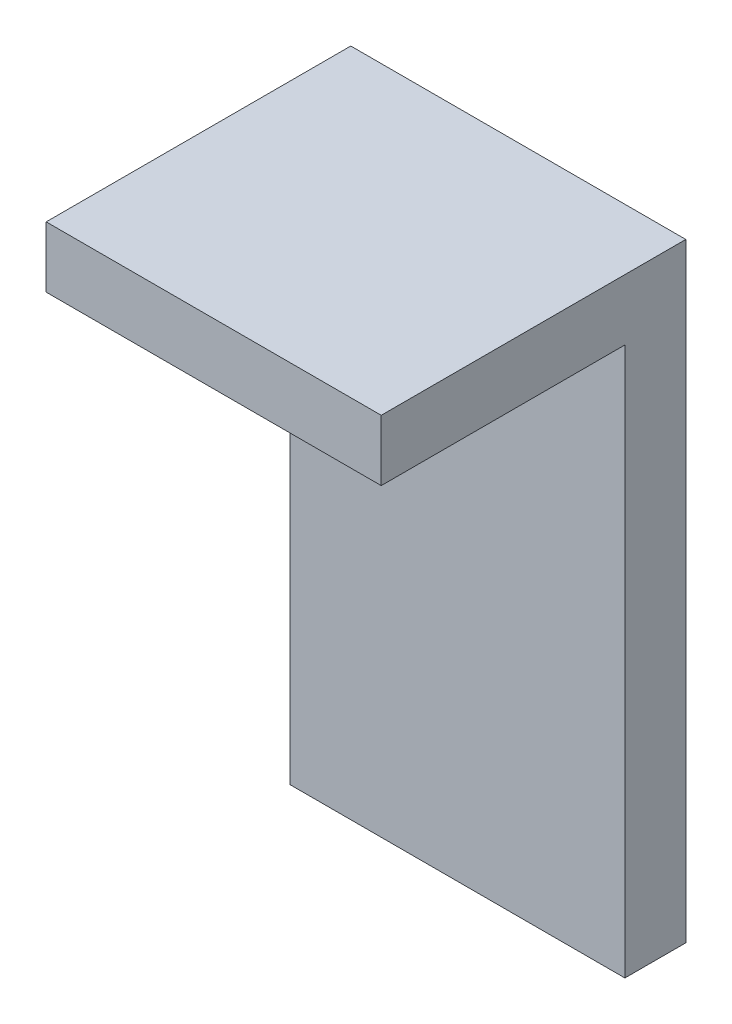
from build123d import *

# Parameters (mm, degrees)
SKETCH1_W           = 55
SKETCH1_H           = 100
BOSS_EXTRUDE1_DEPTH = 10
SKETCH2_W           = 55
SKETCH2_H           = 10
BOSS_EXTRUDE2_DEPTH = 40


with BuildPart() as part:
    # Sketch1 → Boss-Extrude1 (new body)
    with BuildSketch(Plane.XY):
        with Locations((27.5, 50)):
            Rectangle(SKETCH1_W, SKETCH1_H)
    extrude(amount=BOSS_EXTRUDE1_DEPTH)

    # Sketch2 → Boss-Extrude2 (add)
    with BuildSketch(Plane.XY.offset(10)):
        with Locations((27.5, 95)):
            Rectangle(SKETCH2_W, SKETCH2_H)
    extrude(amount=BOSS_EXTRUDE2_DEPTH)


solid = part.part
